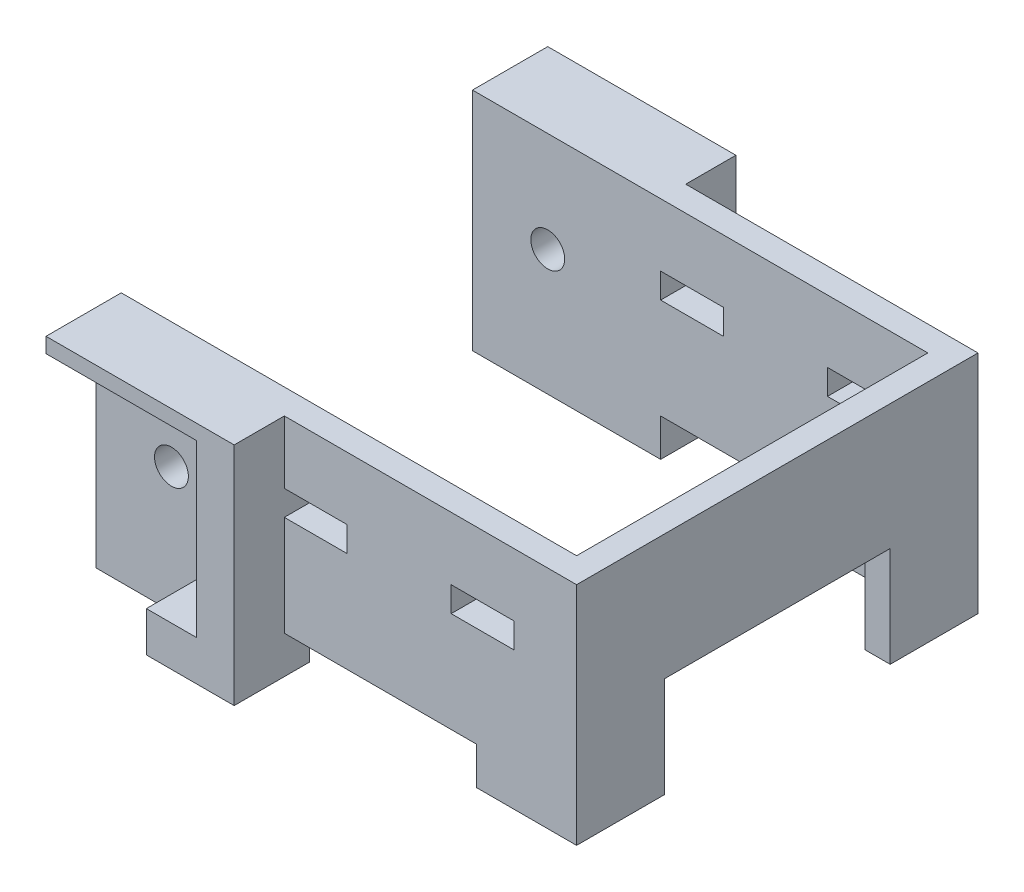
from build123d import *

# Parameters (mm, degrees)
SKETCH_1_W           = 38.3
SKETCH_1_H           = 32
EXTRUDE_1_DEPTH      = 2
EXTRUDE_2_DEPTH      = 75
SKETCH_9_R           = 1.35
CUT_EXTRUDE_5_DEPTH  = 33
SKETCH_10_W          = 15.3
SKETCH_10_H          = 52
CUT_EXTRUDE_6_DEPTH  = 33
SKETCH_11_W          = 28.3
SKETCH_11_H          = 22
CUT_EXTRUDE_7_DEPTH  = 78
SKETCH_13_W          = 18
SKETCH_13_H          = 57
CUT_EXTRUDE_8_DEPTH  = 39.3
SKETCH_14_W          = 5
SKETCH_14_H          = 2
CUT_EXTRUDE_9_DEPTH  = 33
EXTRUDE_3_DEPTH      = 4
EXTRUDE_4_DEPTH      = 4
SKETCH_19_W          = 8
SKETCH_19_H          = 45.4
CUT_EXTRUDE_10_DEPTH = 4
SKETCH_20_W          = 40.713744441
SKETCH_20_H          = 41.376466264
CUT_EXTRUDE_11_DEPTH = 59


with BuildPart() as part:
    # Эскиз1 → Бобышка-Вытянуть1 (new body)
    with BuildSketch(Plane(origin=(0, 0, 0), x_dir=(1, 0, 0), z_dir=(0, 1, 0))):
        Rectangle(SKETCH_1_W, SKETCH_1_H)
    extrude(amount=EXTRUDE_1_DEPTH)

    # Эскиз2 → Бобышка-Вытянуть2 (add)
    with BuildSketch(Plane(origin=(0, 2, 0), x_dir=(1, 0, 0), z_dir=(0, 1, 0))):
        Polygon((-19.15, 16), (19.15, 16), (19.15, -16), (-19.15, -16), (-19.15, -14), (17.15, -14), (17.15, 14), (-19.15, 14), align=None)
    extrude(amount=EXTRUDE_2_DEPTH)

    # Эскиз9 → Вырез-Вытянуть5 (cut, through all)
    with BuildSketch(Plane.XY.offset(16)):
        with Locations((-13.15, 69)):
            Circle(SKETCH_9_R)
        with Locations((-13.15, 10)):
            Circle(SKETCH_9_R)
    extrude(amount=-CUT_EXTRUDE_5_DEPTH, mode=Mode.SUBTRACT)

    # Эскиз10 → Вырез-Вытянуть6 (cut, through all)
    with BuildSketch(Plane.XY.offset(16)):
        with Locations((3.5, 36)):
            Rectangle(SKETCH_10_W, SKETCH_10_H)
    extrude(amount=-CUT_EXTRUDE_6_DEPTH, mode=Mode.SUBTRACT)

    # Эскиз11 → Вырез-Вытянуть7 (cut, through all)
    with BuildSketch(Plane.XZ):
        Rectangle(SKETCH_11_W, SKETCH_11_H)
    extrude(amount=-CUT_EXTRUDE_7_DEPTH, mode=Mode.SUBTRACT)

    # Эскиз13 → Вырез-Вытянуть8 (cut, through all)
    with BuildSketch(Plane(origin=(19.15, 0, 0), x_dir=(0, 0, -1), z_dir=(1, 0, 0))):
        with Locations((0, 38.5)):
            Rectangle(SKETCH_13_W, SKETCH_13_H)
    extrude(amount=-CUT_EXTRUDE_8_DEPTH, mode=Mode.SUBTRACT)

    # Эскиз14 → Вырез-Вытянуть9 (cut, through all)
    with BuildSketch(Plane(origin=(0, 0, -16), x_dir=(-1, 0, 0), z_dir=(0, 0, -1))):
        with Locations((-11.65, 71)):
            Rectangle(SKETCH_14_W, SKETCH_14_H)
        with Locations((1.65, 71)):
            Rectangle(SKETCH_14_W, SKETCH_14_H)
    extrude(amount=-CUT_EXTRUDE_9_DEPTH, mode=Mode.SUBTRACT)

    # Эскиз16 → Бобышка-Вытянуть3 (add)
    with BuildSketch(Plane.XY.offset(16)):
        Polygon((-19.15, 0), (-4.15, 0), (-4.15, 19.8), (-19.15, 19.8), (-19.15, 16.8), (-7.15, 16.8), (-7.15, 3.2), (-19.15, 3.2), align=None)
    extrude_3 = extrude(amount=EXTRUDE_3_DEPTH)

    # Зеркальное отражение1: Бобышка-Вытянуть3 across plane
    add(extrude_3.mirror(Plane.XY))

    # Эскиз18 → Бобышка-Вытянуть4 (add)
    with BuildSketch(Plane.XY.offset(16)):
        Polygon((-19.15, 62.2), (-19.15, 59), (-4.15, 59), (-4.15, 77), (-19.15, 77), (-19.15, 75.8), (-7.15, 75.8), (-7.15, 62.2), align=None)
    extrude_4 = extrude(amount=EXTRUDE_4_DEPTH)

    # Зеркальное отражение2: Бобышка-Вытянуть4 across plane
    add(extrude_4.mirror(Plane.XY))

    # Эскиз19 → Вырез-Вытянуть10 (cut)
    with BuildSketch(Plane.XY.offset(20)):
        with Locations((-15.15, 39.5)):
            Rectangle(SKETCH_19_W, SKETCH_19_H)
    extrude(amount=-CUT_EXTRUDE_10_DEPTH, mode=Mode.SUBTRACT)

    # Эскиз20 → Вырез-Вытянуть11 (cut)
    with BuildSketch(Plane.XZ):
        with Locations((1.20687222, -0.688233132)):
            Rectangle(SKETCH_20_W, SKETCH_20_H)
    extrude(amount=-CUT_EXTRUDE_11_DEPTH, mode=Mode.SUBTRACT)


solid = part.part
